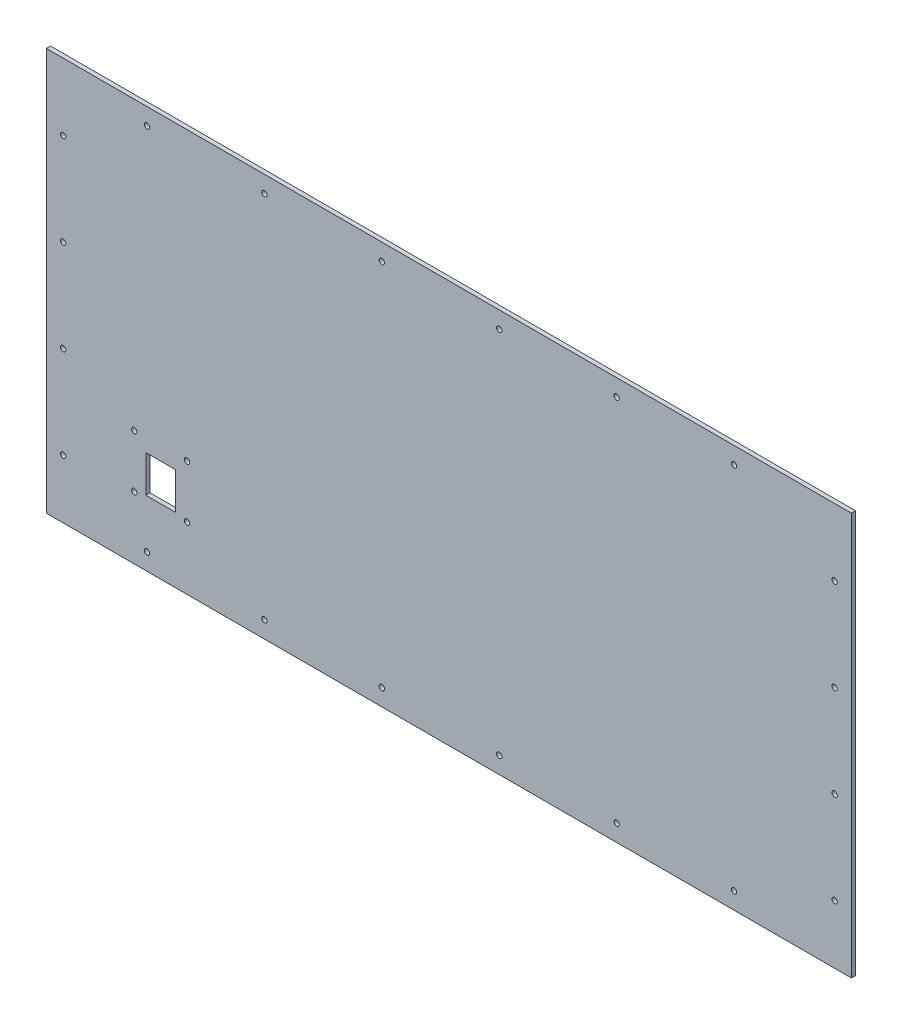
from build123d import *

# Parameters (mm, degrees)
SKETCH1_W           = 609.6
SKETCH1_H           = 304.8
BOSS_EXTRUDE1_DEPTH = 3.175
SKETCH5_R           = 2.032
CUT_EXTRUDE4_DEPTH  = 4.175
SKETCH6_R           = 2.032
CUT_EXTRUDE5_DEPTH  = 3.175
SKETCH7_R           = 2.032
SKETCH7_W           = 22.476650202
SKETCH7_H           = 27.949336331
CUT_EXTRUDE7_DEPTH  = 4.175


with BuildPart() as part:
    # Sketch1 → Boss-Extrude1 (new body)
    with BuildSketch(Plane.XY):
        with Locations((-304.8, 152.4)):
            Rectangle(SKETCH1_W, SKETCH1_H)
    extrude(amount=BOSS_EXTRUDE1_DEPTH)

    # Sketch5 → Cut-Extrude4 (cut, through all)
    with BuildSketch(Plane.XY.offset(3.175)):
        with Locations((-533.4, 12.7)):
            Circle(SKETCH5_R)
        with Locations((-444.5, 12.7)):
            Circle(SKETCH5_R)
        with Locations((-355.6, 12.7)):
            Circle(SKETCH5_R)
        with Locations((-266.7, 12.7)):
            Circle(SKETCH5_R)
        with Locations((-177.8, 12.7)):
            Circle(SKETCH5_R)
        with Locations((-88.9, 12.7)):
            Circle(SKETCH5_R)
        with Locations((-88.9, 292.1)):
            Circle(SKETCH5_R)
        with Locations((-177.8, 292.1)):
            Circle(SKETCH5_R)
        with Locations((-266.7, 292.1)):
            Circle(SKETCH5_R)
        with Locations((-355.6, 292.1)):
            Circle(SKETCH5_R)
        with Locations((-444.5, 292.1)):
            Circle(SKETCH5_R)
        with Locations((-533.4, 292.1)):
            Circle(SKETCH5_R)
    extrude(amount=-CUT_EXTRUDE4_DEPTH, mode=Mode.SUBTRACT)

    # Sketch6 → Cut-Extrude5 (cut)
    with BuildSketch(Plane.XY.offset(3.175)):
        with Locations((-596.9, 254)):
            Circle(SKETCH6_R)
        with Locations((-596.9, 184.15)):
            Circle(SKETCH6_R)
        with Locations((-596.9, 114.3)):
            Circle(SKETCH6_R)
        with Locations((-596.9, 44.45)):
            Circle(SKETCH6_R)
        with Locations((-12.7, 44.45)):
            Circle(SKETCH6_R)
        with Locations((-12.7, 114.3)):
            Circle(SKETCH6_R)
        with Locations((-12.7, 184.15)):
            Circle(SKETCH6_R)
        with Locations((-12.7, 254)):
            Circle(SKETCH6_R)
    extrude(amount=-CUT_EXTRUDE5_DEPTH, mode=Mode.SUBTRACT)

    # Sketch7 → Cut-Extrude7 (cut, through all)
    with BuildSketch(Plane.XY.offset(3.175)):
        with Locations((-543.1, 87.45)):
            Circle(SKETCH7_R)
        with Locations((-503.1, 87.45)):
            Circle(SKETCH7_R)
        with Locations((-503.1, 47.45)):
            Circle(SKETCH7_R)
        with Locations((-543.1, 47.45)):
            Circle(SKETCH7_R)
        with Locations((-523.1, 63.424668166)):
            Rectangle(SKETCH7_W, SKETCH7_H)
    extrude(amount=-CUT_EXTRUDE7_DEPTH, mode=Mode.SUBTRACT)


solid = part.part
